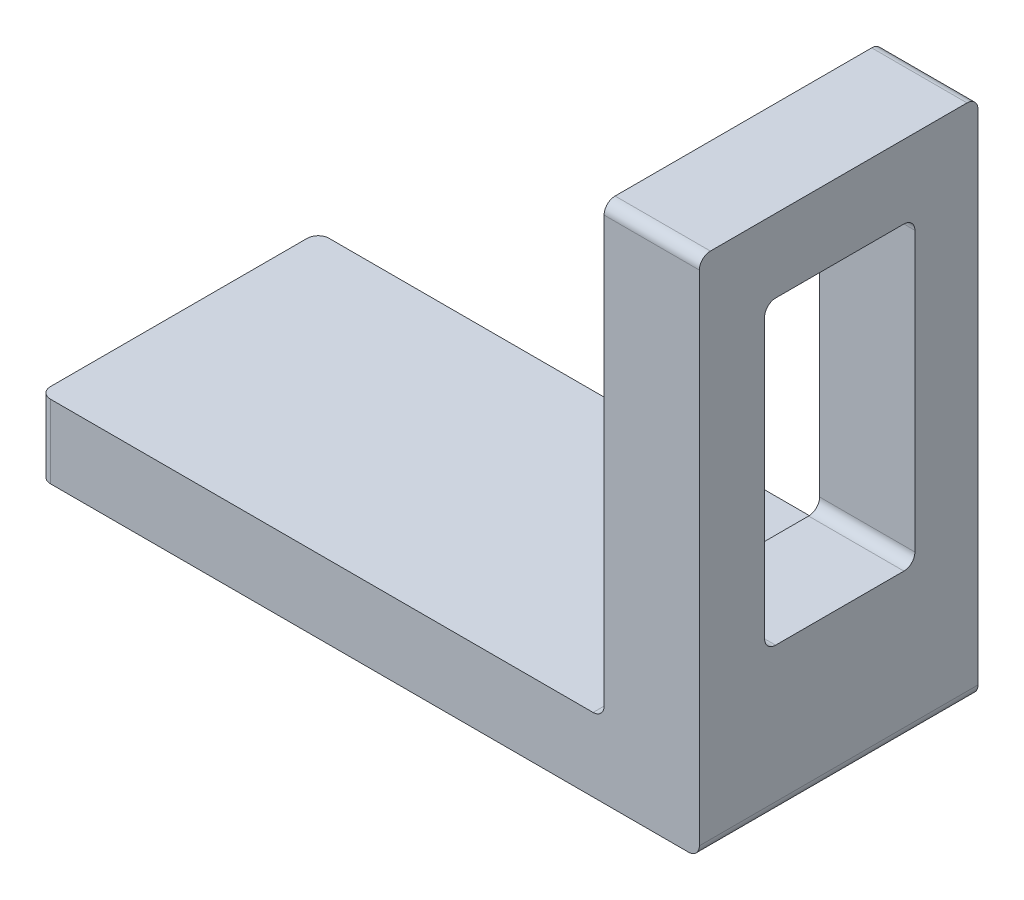
from build123d import *

# Parameters (mm, degrees)
BOSS_EXTRUDE1_DEPTH = 38
SKETCH3_R           = 1.4
CUT_EXTRUDE2_DEPTH  = 8
SKETCH4_W           = 20.5
SKETCH4_H           = 41
CUT_EXTRUDE4_DEPTH  = 14
SKETCH7_R           = 1.4
CUT_EXTRUDE6_DEPTH  = 8
FILLET1_R           = 1.5
FILLET2_R           = 1.5


with BuildPart() as part:
    # Sketch1 → Boss-Extrude1 (new body)
    with BuildSketch(Plane.XY):
        Polygon((0, 0), (90, 0), (90, 71), (77, 71), (77, 10), (0, 10), align=None)
    extrude(amount=BOSS_EXTRUDE1_DEPTH)

    # Sketch3 → Cut-Extrude2 (cut)
    with BuildSketch(Plane.XZ):
        with Locations((23.6, 19)):
            Circle(SKETCH3_R)
        with Locations((34.1, 29.5)):
            Circle(SKETCH3_R)
        with Locations((44.6, 19)):
            Circle(SKETCH3_R)
        with Locations((34.1, 8.5)):
            Circle(SKETCH3_R)
    extrude(amount=-CUT_EXTRUDE2_DEPTH, mode=Mode.SUBTRACT)

    # Sketch4 → Cut-Extrude4 (cut, through all)
    with BuildSketch(Plane.ZY.offset(-77)):
        with Locations((18.854791971, 40.5)):
            Rectangle(SKETCH4_W, SKETCH4_H)
    extrude(amount=-CUT_EXTRUDE4_DEPTH, mode=Mode.SUBTRACT)

    # Sketch7 → Cut-Extrude6 (cut)
    with BuildSketch(Plane.ZY.offset(-77)):
        with Locations((13.906550577, 65.016024352)):
            Circle(SKETCH7_R)
        with Locations((23.806550577, 65.016024352)):
            Circle(SKETCH7_R)
        with Locations((13.906550577, 16.416024352)):
            Circle(SKETCH7_R)
        with Locations((23.806550577, 16.416024352)):
            Circle(SKETCH7_R)
    extrude(amount=-CUT_EXTRUDE6_DEPTH, mode=Mode.SUBTRACT)

    # Fillet1
    fillet1_edges = [part.edges().sort_by_distance(p)[0] for p in [
        (83.5, 20, 8.604791971),
        (83.5, 61, 8.604791971),
        (83.5, 61, 29.104791971),
        (83.5, 20, 29.104791971),
    ]]
    fillet(fillet1_edges, radius=FILLET1_R)

    # Fillet2
    fillet2_edges = [part.edges().sort_by_distance(p)[0] for p in [
        (77, 10, 19),
        (90, 0, 19),
        (83.5, 71, 38),
        (0, 5, 38),
        (83.5, 71, 0),
        (0, 5, 0),
    ]]
    fillet(fillet2_edges, radius=FILLET2_R)


solid = part.part
